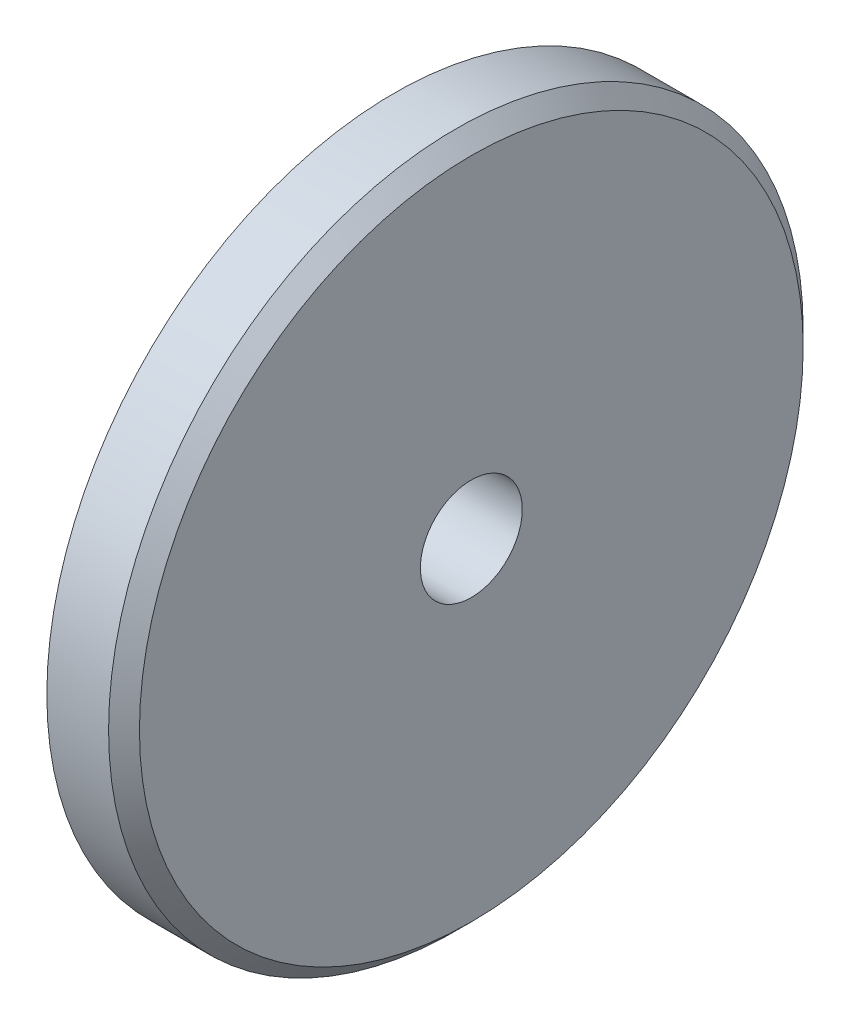
from build123d import *

# Parameters (mm, degrees)
SKETCH_1_R      = 22.5
SKETCH_1_R_2    = 3.3
EXTRUDE_1_DEPTH = 5
CHAMFER_1_SIZE  = 1


with BuildPart() as part:
    # 草图1 → 凸台-拉伸1 (new body)
    with BuildSketch(Plane(origin=(0, 0, 0), x_dir=(0, 0, -1), z_dir=(1, 0, 0))):
        Circle(SKETCH_1_R)
        Circle(SKETCH_1_R_2, mode=Mode.SUBTRACT)
    extrude(amount=EXTRUDE_1_DEPTH)

    # 倒角1
    chamfer_1_edges = [part.edges().sort_by_distance(p)[0] for p in [
        (5, 0, 22.5),
    ]]
    chamfer(chamfer_1_edges, length=CHAMFER_1_SIZE)


solid = part.part
